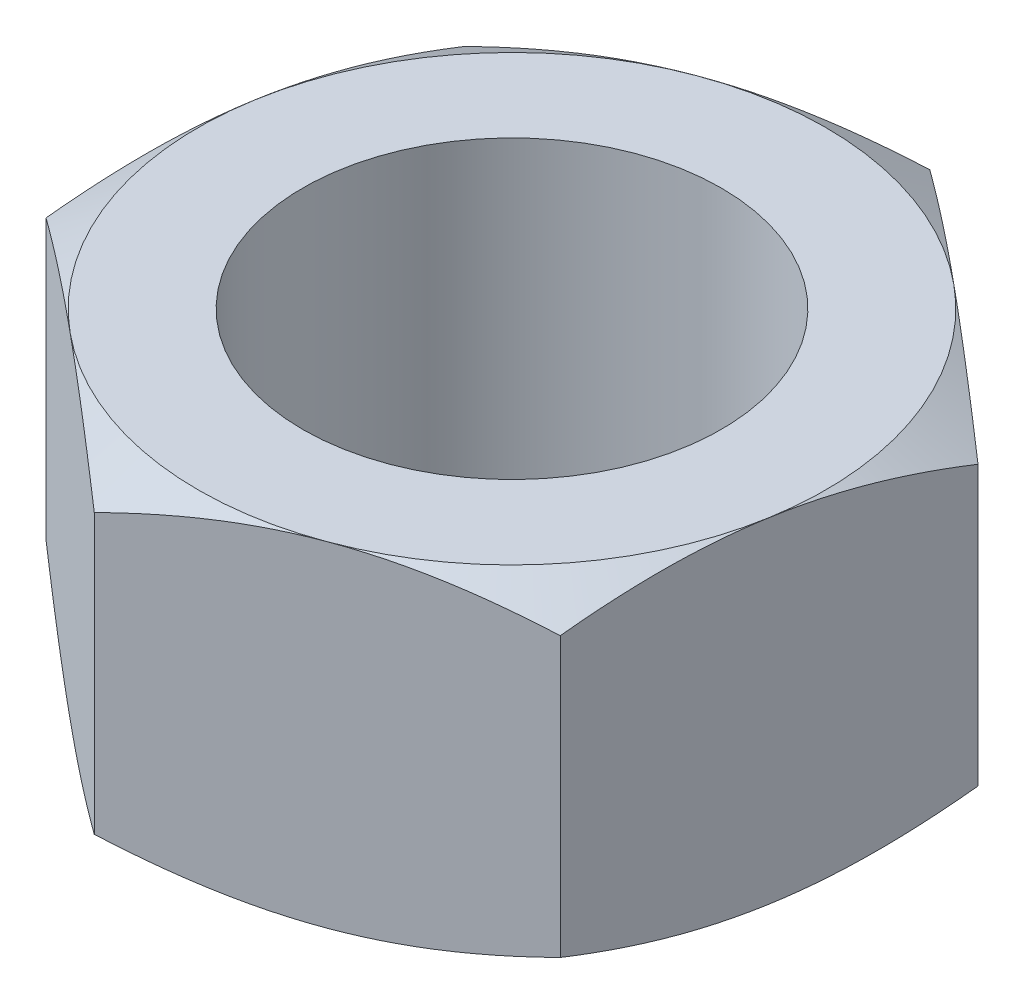
from build123d import *

# Parameters (mm, degrees)
BOSS_EXTRUDE1_DEPTH = 8
SKETCH7_OUTSIDE_W   = 26.674
SKETCH7_OUTSIDE_H   = 27.518
SKETCH7_OUTSIDE_R   = 7.5
CUT_EXTRUDE4_DEPTH  = 1
CUT_EXTRUDE4_TAPER  = 60
SKETCH8_OUTSIDE_W   = 26.674
SKETCH8_OUTSIDE_H   = 27.518
SKETCH8_OUTSIDE_R   = 7.5
CUT_EXTRUDE5_DEPTH  = 1
CUT_EXTRUDE5_TAPER  = 60
SKETCH9_R           = 5
CUT_EXTRUDE6_DEPTH  = 10


with BuildPart() as part:
    # Sketch1 → Boss-Extrude1 (new body)
    with BuildSketch(Plane(origin=(0, 0, 0), x_dir=(1, 0, 0), z_dir=(0, 1, 0))):
        Polygon((6.673205692, -5.519812116), (8.116900362, 3.019259596), (1.44369467, 8.539071712), (-6.673205692, 5.519812116), (-8.116900362, -3.019259596), (-1.44369467, -8.539071712), align=None)
    extrude(amount=BOSS_EXTRUDE1_DEPTH)

    # Sketch7 outside → Cut-Extrude4 (cut)
    with BuildSketch(Plane(origin=(0, 8, 0), x_dir=(1, 0, 0), z_dir=(0, 1, 0))):
        Rectangle(SKETCH7_OUTSIDE_W, SKETCH7_OUTSIDE_H)
        Circle(SKETCH7_OUTSIDE_R, mode=Mode.SUBTRACT)
    extrude(amount=-CUT_EXTRUDE4_DEPTH, taper=CUT_EXTRUDE4_TAPER, mode=Mode.SUBTRACT)

    # Sketch8 outside → Cut-Extrude5 (cut)
    with BuildSketch(Plane.XZ):
        Rectangle(SKETCH8_OUTSIDE_W, SKETCH8_OUTSIDE_H)
        Circle(SKETCH8_OUTSIDE_R, mode=Mode.SUBTRACT)
    extrude(amount=-CUT_EXTRUDE5_DEPTH, taper=CUT_EXTRUDE5_TAPER, mode=Mode.SUBTRACT)

    # Sketch9 → Cut-Extrude6 (cut)
    with BuildSketch(Plane(origin=(0, 8, 0), x_dir=(1, 0, 0), z_dir=(0, 1, 0))):
        Circle(SKETCH9_R)
    extrude(amount=-CUT_EXTRUDE6_DEPTH, mode=Mode.SUBTRACT)


solid = part.part
